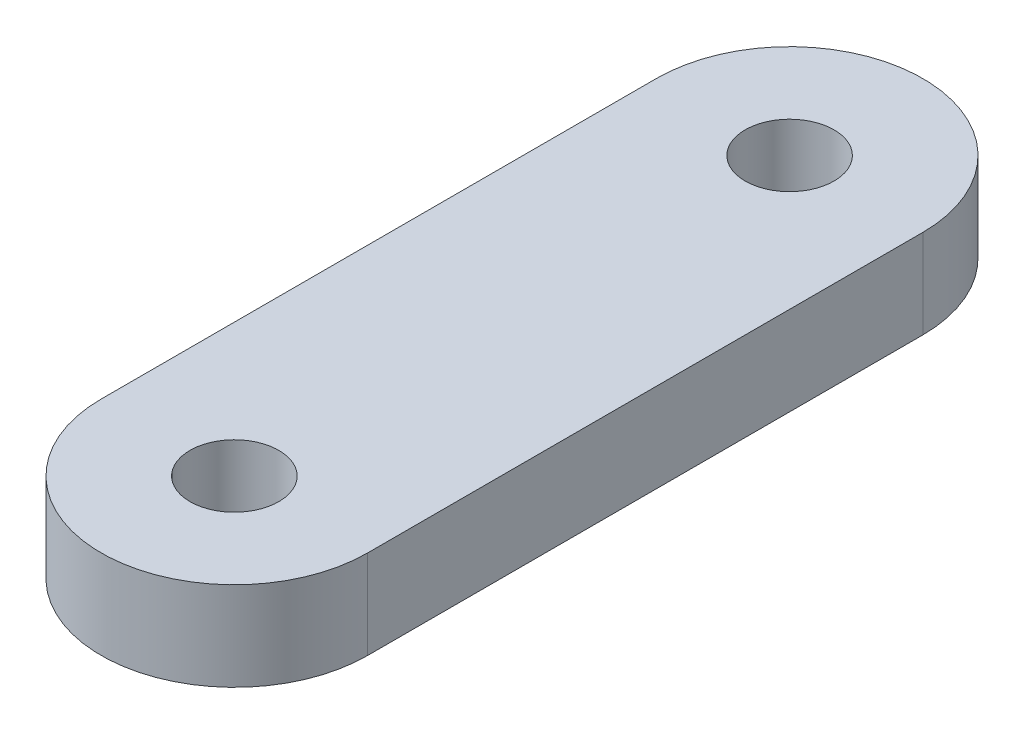
from build123d import *

# Parameters (mm, degrees)
BOSS_EXTRUDE1_DEPTH = 4
SKETCH2_R           = 2
CUT_EXTRUDE3_DEPTH  = 5


with BuildPart() as part:
    # Sketch1 → Boss-Extrude1 (new body)
    with BuildSketch(Plane(origin=(0, 0, 0), x_dir=(1, 0, 0), z_dir=(0, 1, 0))):
        with BuildLine():
            Line((6, 12.5), (6, -12.5))
            ThreePointArc((6, -12.5), (0, -18.5), (-6, -12.5))
            Line((-6, -12.5), (-6, 12.5))
            ThreePointArc((-6, 12.5), (0, 18.5), (6, 12.5))
        make_face()
    extrude(amount=BOSS_EXTRUDE1_DEPTH)

    # Sketch2 → Cut-Extrude3 (cut, through all)
    with BuildSketch(Plane(origin=(0, 4, 0), x_dir=(1, 0, 0), z_dir=(0, 1, 0))):
        with Locations((0, 12.5)):
            Circle(SKETCH2_R)
        with Locations((0, -12.5)):
            Circle(SKETCH2_R)
    extrude(amount=-CUT_EXTRUDE3_DEPTH, mode=Mode.SUBTRACT)


solid = part.part
